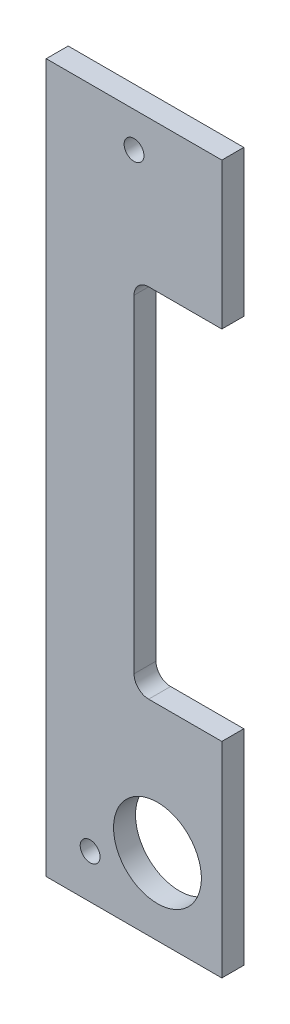
from build123d import *

# Parameters (mm, degrees)
BOSS_EXTRUDE1_DEPTH         = 4.7625
F_6_CLEARANCE_HOLE1_D       = 4.3053
F_3_4_0_75_DIAMETER_HOLE1_D = 19.05


with BuildPart() as part:
    # Sketch1 → Boss-Extrude1 (new body)
    with BuildSketch(Plane.XY):
        with BuildLine():
            Line((0, 44.45), (-15.875, 44.45))
            ThreePointArc((-15.875, 44.45), (-18.12006403, 45.37993597), (-19.05, 47.625))
            Line((-19.05, 47.625), (-19.05, 118.745))
            ThreePointArc((-19.05, 118.745), (-18.12006403, 120.99006403), (-15.875, 121.92))
            Line((-15.875, 121.92), (0, 121.92))
            Line((0, 121.92), (0, 153.67))
            Line((0, 153.67), (-38.1, 153.67))
            Line((-38.1, 153.67), (-38.1, 0))
            Line((-38.1, 0), (0, 0))
            Line((0, 0), (0, 44.45))
        make_face()
    extrude(amount=-BOSS_EXTRUDE1_DEPTH)

    # #6 Clearance Hole1 (through all)
    with Locations(Plane(origin=(0, 0, -4.7625), x_dir=(-1, 0, 0), z_dir=(0, 0, -1))):
        with Locations((28.575, 9.525), (19.05, 146.05)):
            Hole(F_6_CLEARANCE_HOLE1_D / 2)

    # 3/4 (0.75) Diameter Hole1 (through all)
    with Locations(Plane(origin=(0, 0, -4.7625), x_dir=(-1, 0, 0), z_dir=(0, 0, -1))):
        with Locations((13.97, 16.51)):
            Hole(F_3_4_0_75_DIAMETER_HOLE1_D / 2)


solid = part.part
